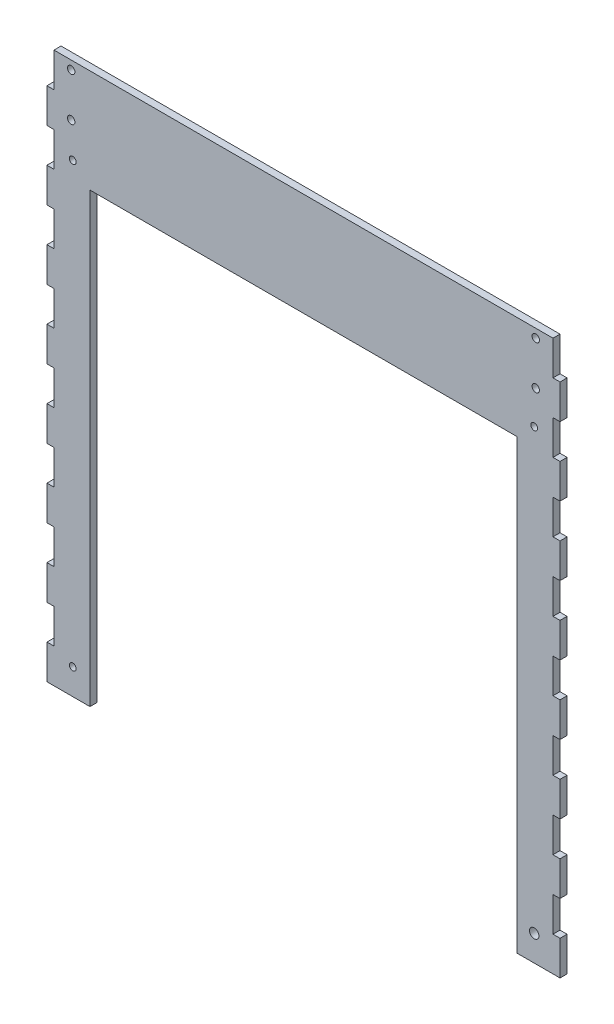
from build123d import *

# Parameters (mm, degrees)
SKETCH1_R           = 2.5
SKETCH1_R_2         = 3.5
SKETCH1_R_3         = 2.75
BOSS_EXTRUDE1_DEPTH = 5.207


with BuildPart() as part:
    # Sketch1 → Boss-Extrude1 (new body)
    with BuildSketch(Plane.XY):
        Polygon((-189.357, 25.4), (-189.357, 0), (-157.607, 0), (-157.607, 330.2), (157.607, 330.2), (157.607, 0), (189.357, 0), (189.357, 25.4), (184.15, 25.4), (184.15, 50.8), (189.357, 50.8), (189.357, 76.2), (184.15, 76.2), (184.15, 101.6), (189.357, 101.6), (189.357, 127), (184.15, 127), (184.15, 152.4), (189.357, 152.4), (189.357, 177.8), (184.15, 177.8), (184.15, 203.2), (189.357, 203.2), (189.357, 228.6), (184.15, 228.6), (184.15, 254), (189.357, 254), (189.357, 279.4), (184.15, 279.4), (184.15, 304.8), (189.357, 304.8), (189.357, 330.2), (184.15, 330.2), (184.15, 355.6), (189.357, 355.6), (189.357, 381), (184.15, 381), (184.15, 406.4), (-184.15, 406.4), (-184.15, 381), (-189.357, 381), (-189.357, 355.6), (-184.15, 355.6), (-184.15, 330.2), (-189.357, 330.2), (-189.357, 304.8), (-184.15, 304.8), (-184.15, 279.4), (-189.357, 279.4), (-189.357, 254), (-184.15, 254), (-184.15, 228.6), (-189.357, 228.6), (-189.357, 203.2), (-184.15, 203.2), (-184.15, 177.8), (-189.357, 177.8), (-189.357, 152.4), (-184.15, 152.4), (-184.15, 127), (-189.357, 127), (-189.357, 101.6), (-184.15, 101.6), (-184.15, 76.2), (-189.357, 76.2), (-189.357, 50.8), (-184.15, 50.8), (-184.15, 25.4), align=None)
        with Locations((-170.307, 19.05)):
            Circle(SKETCH1_R, mode=Mode.SUBTRACT)
        with Locations((170.307, 19.05)):
            Circle(SKETCH1_R_2, mode=Mode.SUBTRACT)
        with Locations((-170.307, 342.9)):
            Circle(SKETCH1_R, mode=Mode.SUBTRACT)
        with Locations((-171.45, 368.05)):
            Circle(SKETCH1_R_3, mode=Mode.SUBTRACT)
        with Locations((-171.45, 400.05)):
            Circle(SKETCH1_R_3, mode=Mode.SUBTRACT)
        with Locations((170.307, 342.9)):
            Circle(SKETCH1_R, mode=Mode.SUBTRACT)
        with Locations((171.45, 368.05)):
            Circle(SKETCH1_R_3, mode=Mode.SUBTRACT)
        with Locations((171.45, 400.05)):
            Circle(SKETCH1_R_3, mode=Mode.SUBTRACT)
    extrude(amount=BOSS_EXTRUDE1_DEPTH)


solid = part.part
